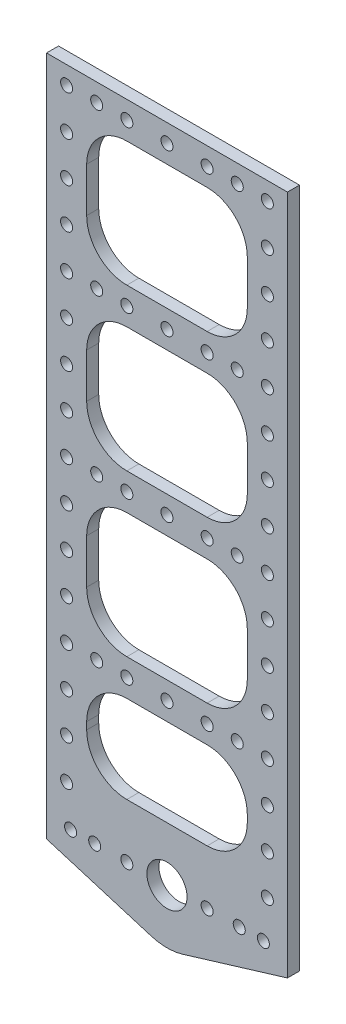
from build123d import *

# Parameters (mm, degrees)
SKETCH1_W           = 40
SKETCH1_H           = 31.068216144
SKETCH1_R           = 1.5
SKETCH1_H_2         = 21.795351568
SKETCH1_R_2         = 5
BOSS_EXTRUDE1_DEPTH = 3
FILLET1_R           = 10


with BuildPart() as part:
    # Sketch1 → Boss-Extrude1 (new body)
    with BuildSketch(Plane.XY):
        with BuildLine():
            Line((-29.546509682, -3.213846621), (-3.468555942, -11.131569065))
            ThreePointArc((-3.468555942, -11.131569065), (0.453490318, -11.713846621), (4.375536577, -11.131569065))
            Line((4.375536577, -11.131569065), (30.453490318, -3.213846621))
            Line((30.453490318, -3.213846621), (30.453490318, 166.286153379))
            Line((30.453490318, 166.286153379), (-29.546509682, 166.286153379))
            Line((-29.546509682, 166.286153379), (-29.546509682, -3.213846621))
        make_face()
        with Locations((0.453490318, 141.752045307)):
            Rectangle(SKETCH1_W, SKETCH1_H, mode=Mode.SUBTRACT)
        with Locations((0.453490318, 101.683829163)):
            Rectangle(SKETCH1_W, SKETCH1_H, mode=Mode.SUBTRACT)
        with Locations((0.453490318, 121.717937235)):
            Circle(SKETCH1_R, mode=Mode.SUBTRACT)
        with Locations((0.453490318, 61.615613019)):
            Rectangle(SKETCH1_W, SKETCH1_H, mode=Mode.SUBTRACT)
        with Locations((0.453490318, 81.649721091)):
            Circle(SKETCH1_R, mode=Mode.SUBTRACT)
        with Locations((0.453490318, 26.183829163)):
            Rectangle(SKETCH1_W, SKETCH1_H_2, mode=Mode.SUBTRACT)
        with Locations((0.453490318, 41.581504947)):
            Circle(SKETCH1_R, mode=Mode.SUBTRACT)
        with Locations((0.453490318, 161.786153379)):
            Circle(SKETCH1_R, mode=Mode.SUBTRACT)
        with Locations((10.453490318, 161.786153379)):
            Circle(SKETCH1_R, mode=Mode.SUBTRACT)
        with Locations((17.953490318, 161.786153379)):
            Circle(SKETCH1_R, mode=Mode.SUBTRACT)
        with Locations((25.453490318, 161.786153379)):
            Circle(SKETCH1_R, mode=Mode.SUBTRACT)
        with Locations((24.453490318, 1.786153379)):
            Circle(SKETCH1_R, mode=Mode.SUBTRACT)
        with Locations((18.453490318, 1.786153379)):
            Circle(SKETCH1_R, mode=Mode.SUBTRACT)
        with Locations((10.453490318, 1.786153379)):
            Circle(SKETCH1_R, mode=Mode.SUBTRACT)
        with Locations((0.453490318, 1.786153379)):
            Circle(SKETCH1_R_2, mode=Mode.SUBTRACT)
        with Locations((-9.546509682, 161.786153379)):
            Circle(SKETCH1_R, mode=Mode.SUBTRACT)
        with Locations((-17.046509682, 161.786153379)):
            Circle(SKETCH1_R, mode=Mode.SUBTRACT)
        with Locations((-24.546509682, 161.786153379)):
            Circle(SKETCH1_R, mode=Mode.SUBTRACT)
        with Locations((-9.546509682, 1.786153379)):
            Circle(SKETCH1_R, mode=Mode.SUBTRACT)
        with Locations((-17.546509682, 1.786153379)):
            Circle(SKETCH1_R, mode=Mode.SUBTRACT)
        with Locations((-23.546509682, 1.786153379)):
            Circle(SKETCH1_R, mode=Mode.SUBTRACT)
        with Locations((-24.546509682, 11.581504947)):
            Circle(SKETCH1_R, mode=Mode.SUBTRACT)
        with Locations((-24.546509682, 21.581504947)):
            Circle(SKETCH1_R, mode=Mode.SUBTRACT)
        with Locations((-24.546509682, 31.581504947)):
            Circle(SKETCH1_R, mode=Mode.SUBTRACT)
        with Locations((-24.546509682, 41.581504947)):
            Circle(SKETCH1_R, mode=Mode.SUBTRACT)
        with Locations((-24.546509682, 51.649721091)):
            Circle(SKETCH1_R, mode=Mode.SUBTRACT)
        with Locations((-24.546509682, 61.649721091)):
            Circle(SKETCH1_R, mode=Mode.SUBTRACT)
        with Locations((-24.546509682, 71.649721091)):
            Circle(SKETCH1_R, mode=Mode.SUBTRACT)
        with Locations((-24.546509682, 81.649721091)):
            Circle(SKETCH1_R, mode=Mode.SUBTRACT)
        with Locations((-24.546509682, 91.717937235)):
            Circle(SKETCH1_R, mode=Mode.SUBTRACT)
        with Locations((-24.546509682, 101.717937235)):
            Circle(SKETCH1_R, mode=Mode.SUBTRACT)
        with Locations((-24.546509682, 111.717937235)):
            Circle(SKETCH1_R, mode=Mode.SUBTRACT)
        with Locations((-24.546509682, 121.717937235)):
            Circle(SKETCH1_R, mode=Mode.SUBTRACT)
        with Locations((-24.546509682, 131.786153379)):
            Circle(SKETCH1_R, mode=Mode.SUBTRACT)
        with Locations((-24.546509682, 141.786153379)):
            Circle(SKETCH1_R, mode=Mode.SUBTRACT)
        with Locations((-24.546509682, 151.786153379)):
            Circle(SKETCH1_R, mode=Mode.SUBTRACT)
        with Locations((25.453490318, 111.717937235)):
            Circle(SKETCH1_R, mode=Mode.SUBTRACT)
        with Locations((25.453490318, 151.786153379)):
            Circle(SKETCH1_R, mode=Mode.SUBTRACT)
        with Locations((25.453490318, 141.786153379)):
            Circle(SKETCH1_R, mode=Mode.SUBTRACT)
        with Locations((25.453490318, 131.786153379)):
            Circle(SKETCH1_R, mode=Mode.SUBTRACT)
        with Locations((25.453490318, 121.717937235)):
            Circle(SKETCH1_R, mode=Mode.SUBTRACT)
        with Locations((25.453490318, 11.581504947)):
            Circle(SKETCH1_R, mode=Mode.SUBTRACT)
        with Locations((25.453490318, 21.581504947)):
            Circle(SKETCH1_R, mode=Mode.SUBTRACT)
        with Locations((25.453490318, 31.581504947)):
            Circle(SKETCH1_R, mode=Mode.SUBTRACT)
        with Locations((25.453490318, 41.581504947)):
            Circle(SKETCH1_R, mode=Mode.SUBTRACT)
        with Locations((25.453490318, 51.649721091)):
            Circle(SKETCH1_R, mode=Mode.SUBTRACT)
        with Locations((25.453490318, 61.649721091)):
            Circle(SKETCH1_R, mode=Mode.SUBTRACT)
        with Locations((25.453490318, 71.649721091)):
            Circle(SKETCH1_R, mode=Mode.SUBTRACT)
        with Locations((25.453490318, 81.649721091)):
            Circle(SKETCH1_R, mode=Mode.SUBTRACT)
        with Locations((25.453490318, 91.717937235)):
            Circle(SKETCH1_R, mode=Mode.SUBTRACT)
        with Locations((25.453490318, 101.717937235)):
            Circle(SKETCH1_R, mode=Mode.SUBTRACT)
        with Locations((-9.546509682, 41.581504947)):
            Circle(SKETCH1_R, mode=Mode.SUBTRACT)
        with Locations((-17.046509682, 41.581504947)):
            Circle(SKETCH1_R, mode=Mode.SUBTRACT)
        with Locations((10.453490318, 41.581504947)):
            Circle(SKETCH1_R, mode=Mode.SUBTRACT)
        with Locations((17.953490318, 41.581504947)):
            Circle(SKETCH1_R, mode=Mode.SUBTRACT)
        with Locations((-9.546509682, 81.649721091)):
            Circle(SKETCH1_R, mode=Mode.SUBTRACT)
        with Locations((-17.046509682, 81.649721091)):
            Circle(SKETCH1_R, mode=Mode.SUBTRACT)
        with Locations((10.453490318, 81.649721091)):
            Circle(SKETCH1_R, mode=Mode.SUBTRACT)
        with Locations((17.953490318, 81.649721091)):
            Circle(SKETCH1_R, mode=Mode.SUBTRACT)
        with Locations((-9.546509682, 121.717937235)):
            Circle(SKETCH1_R, mode=Mode.SUBTRACT)
        with Locations((-17.046509682, 121.717937235)):
            Circle(SKETCH1_R, mode=Mode.SUBTRACT)
        with Locations((17.953490318, 121.717937235)):
            Circle(SKETCH1_R, mode=Mode.SUBTRACT)
        with Locations((10.453490318, 121.717937235)):
            Circle(SKETCH1_R, mode=Mode.SUBTRACT)
    extrude(amount=BOSS_EXTRUDE1_DEPTH)

    # Fillet1
    fillet1_edges = [part.edges().sort_by_distance(p)[0] for p in [
        (20.453490318, 157.286153379, 1.5),
        (-19.546509682, 157.286153379, 1.5),
        (-19.546509682, 126.217937235, 1.5),
        (20.453490318, 126.217937235, 1.5),
        (-19.546509682, 37.081504947, 1.5),
        (-19.546509682, 15.286153379, 1.5),
        (20.453490318, 15.286153379, 1.5),
        (20.453490318, 37.081504947, 1.5),
        (-19.546509682, 77.149721091, 1.5),
        (-19.546509682, 46.081504947, 1.5),
        (20.453490318, 46.081504947, 1.5),
        (20.453490318, 77.149721091, 1.5),
        (-19.546509682, 117.217937235, 1.5),
        (-19.546509682, 86.149721091, 1.5),
        (20.453490318, 86.149721091, 1.5),
        (20.453490318, 117.217937235, 1.5),
    ]]
    fillet(fillet1_edges, radius=FILLET1_R)


solid = part.part
